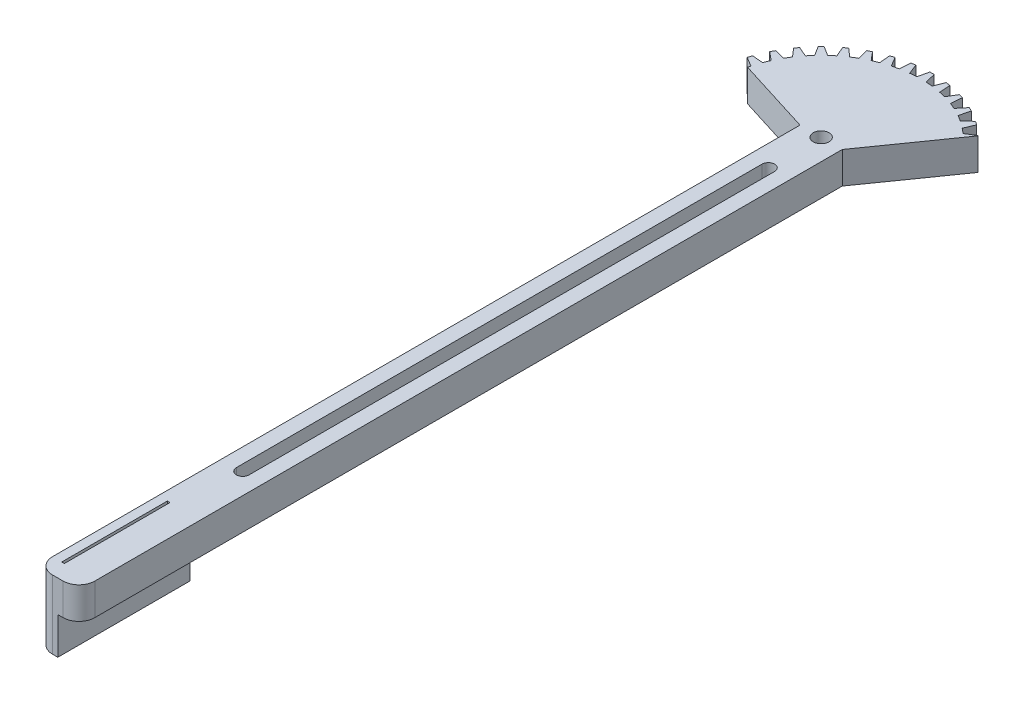
from build123d import *

# Parameters (mm, degrees)
SKETCH1_R           = 21
SKETCH1_R_2         = 1.5
BOSS_EXTRUDE1_DEPTH = 6
CUT_EXTRUDE1_DEPTH  = 6
CIRPATTERN1_COUNT   = 40
CUT_EXTRUDE2_REACH  = 8
BOSS_EXTRUDE2_DEPTH = 6
BOSS_EXTRUDE3_DEPTH = 7
CUT_EXTRUDE4_REACH  = 15
SKETCH7_W           = 0.5
SKETCH7_H           = 20
CUT_EXTRUDE5_REACH  = 8


with BuildPart() as part:
    # Sketch1 → Boss-Extrude1 (new body)
    with BuildSketch(Plane(origin=(0, 0, 0), x_dir=(1, 0, 0), z_dir=(0, 1, 0))):
        Circle(SKETCH1_R)
        Circle(SKETCH1_R_2, mode=Mode.SUBTRACT)
    extrude(amount=BOSS_EXTRUDE1_DEPTH)

    # Sketch2 → Cut-Extrude1 (cut)
    with BuildSketch(Plane(origin=(0, 6, 0), x_dir=(1, 0, 0), z_dir=(0, 1, 0))):
        with BuildLine():
            Line((-0.870178472, 18.980062946), (-0.412307542, 20.99595205))
            ThreePointArc((-0.412307542, 20.99595205), (0, 21), (0.412307542, 20.99595205))
            Line((0.412307542, 20.99595205), (0.870178472, 18.980062946))
            ThreePointArc((0.870178472, 18.980062946), (1.180608684, 18.963284608), (1.490722819, 18.941429341))
            Line((1.490722819, 18.941429341), (1.73143755, 22))
            Line((1.73143755, 22), (-1.73143755, 22))
            Line((-1.73143755, 22), (-1.490722819, 18.941429341))
            ThreePointArc((-1.490722819, 18.941429341), (-1.180608684, 18.963284608), (-0.870178472, 18.980062946))
        make_face()
    cut_extrude1 = extrude(amount=-CUT_EXTRUDE1_DEPTH, mode=Mode.SUBTRACT)

    # CirPattern1: Cut-Extrude1 ×40 about axis
    cirpattern1_axis = Axis((0, 0, 0), (0, 1, 0))
    for i in range(1, CIRPATTERN1_COUNT):
        add(cut_extrude1.rotate(cirpattern1_axis, i * 360 / CIRPATTERN1_COUNT), mode=Mode.SUBTRACT)

    # Sketch3 → Cut-Extrude2 (cut, up to next)
    with BuildSketch(Plane(origin=(0, 6, 0), x_dir=(1, 0, 0), z_dir=(0, 1, 0)), mode=Mode.PRIVATE) as cut_extrude2_sk1:
        with BuildLine():
            Line((-4, 0), (-20.367312321, 5.115915248))
            ThreePointArc((-20.367312321, 5.115915248), (5.753143593, -20.196567501), (14.614168728, 15.080652253))
            Line((14.614168728, 15.080652253), (4, 0))
            Line((4, 0), (-4, 0))
        make_face()
    cut_extrude2_tool1 = extrude(cut_extrude2_sk1.sketch, amount=-CUT_EXTRUDE2_REACH, mode=Mode.PRIVATE) & part.part
    add(cut_extrude2_tool1.solids().sort_by_distance((1.540678, 6, 6.01351))[0], mode=Mode.SUBTRACT)

    # Sketch4 → Boss-Extrude2 (add)
    with BuildSketch(Plane.XZ):
        with BuildLine():
            Line((1.5, 0), (4, 0))
            Line((4, 0), (4, 141.5))
            ThreePointArc((4, 141.5), (3.121320344, 143.621320344), (1, 144.5))
            Line((1, 144.5), (-1, 144.5))
            ThreePointArc((-1, 144.5), (-3.121320344, 143.621320344), (-4, 141.5))
            Line((-4, 141.5), (-4, 0))
            Line((-4, 0), (-1.5, 0))
            ThreePointArc((-1.5, 0), (0, 1.5), (1.5, 0))
        make_face()
    extrude(amount=-BOSS_EXTRUDE2_DEPTH)

    # Sketch5 → Boss-Extrude3 (add)
    with BuildSketch(Plane.XZ):
        with BuildLine():
            Line((-4, 141.5), (-4, 119.5))
            Line((-4, 119.5), (0, 119.5))
            Line((0, 119.5), (0, 144.5))
            Line((0, 144.5), (-1, 144.5))
            ThreePointArc((-1, 144.5), (-3.121320344, 143.621320344), (-4, 141.5))
        make_face()
    extrude(amount=BOSS_EXTRUDE3_DEPTH)

    # Sketch7 → Cut-Extrude4 (cut, up to next)
    with BuildSketch(Plane.XZ.offset(7), mode=Mode.PRIVATE) as cut_extrude4_sk1:
        with Locations((-2, 131.5)):
            Rectangle(SKETCH7_W, SKETCH7_H)
    cut_extrude4_tool1 = extrude(cut_extrude4_sk1.sketch, amount=-CUT_EXTRUDE4_REACH, mode=Mode.PRIVATE) & part.part
    add(cut_extrude4_tool1.solids().sort_by_distance((-2, -7, 131.5))[0], mode=Mode.SUBTRACT)

    # Sketch8 → Cut-Extrude5 (cut, up to next)
    with BuildSketch(Plane.XZ, mode=Mode.PRIVATE) as cut_extrude5_sk1:
        with BuildLine():
            Line((-1.2, 10), (-1.2, 109.5))
            ThreePointArc((-1.2, 109.5), (0, 110.7), (1.2, 109.5))
            Line((1.2, 109.5), (1.2, 10))
            ThreePointArc((1.2, 10), (0, 8.8), (-1.2, 10))
        make_face()
    cut_extrude5_tool1 = extrude(cut_extrude5_sk1.sketch, amount=-CUT_EXTRUDE5_REACH, mode=Mode.PRIVATE) & part.part
    add(cut_extrude5_tool1.solids().sort_by_distance((0, 0, 59.75))[0], mode=Mode.SUBTRACT)


solid = part.part
